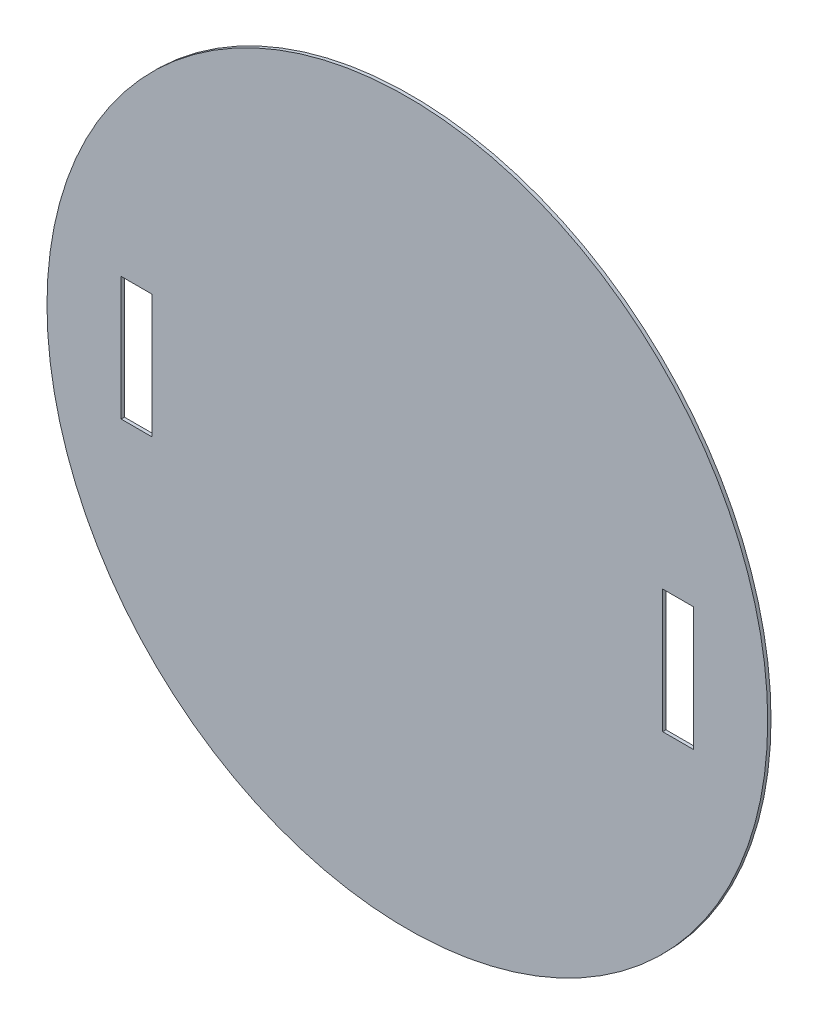
from build123d import *

# Parameters (mm, degrees)
SKETCH1_R           = 175
BOSS_EXTRUDE1_DEPTH = 1.6
SKETCH2_W           = 15
SKETCH2_H           = 60
CUT_EXTRUDE1_DEPTH  = 2.6


with BuildPart() as part:
    # Sketch1 → Boss-Extrude1 (new body)
    with BuildSketch(Plane.XY):
        Circle(SKETCH1_R)
    extrude(amount=BOSS_EXTRUDE1_DEPTH)

    # Sketch2 → Cut-Extrude1 (cut, through all)
    with BuildSketch(Plane.XY.offset(1.6)):
        with Locations((-131.5, 0)):
            Rectangle(SKETCH2_W, SKETCH2_H)
        with Locations((131.5, 0)):
            Rectangle(SKETCH2_W, SKETCH2_H)
    extrude(amount=-CUT_EXTRUDE1_DEPTH, mode=Mode.SUBTRACT)


solid = part.part
